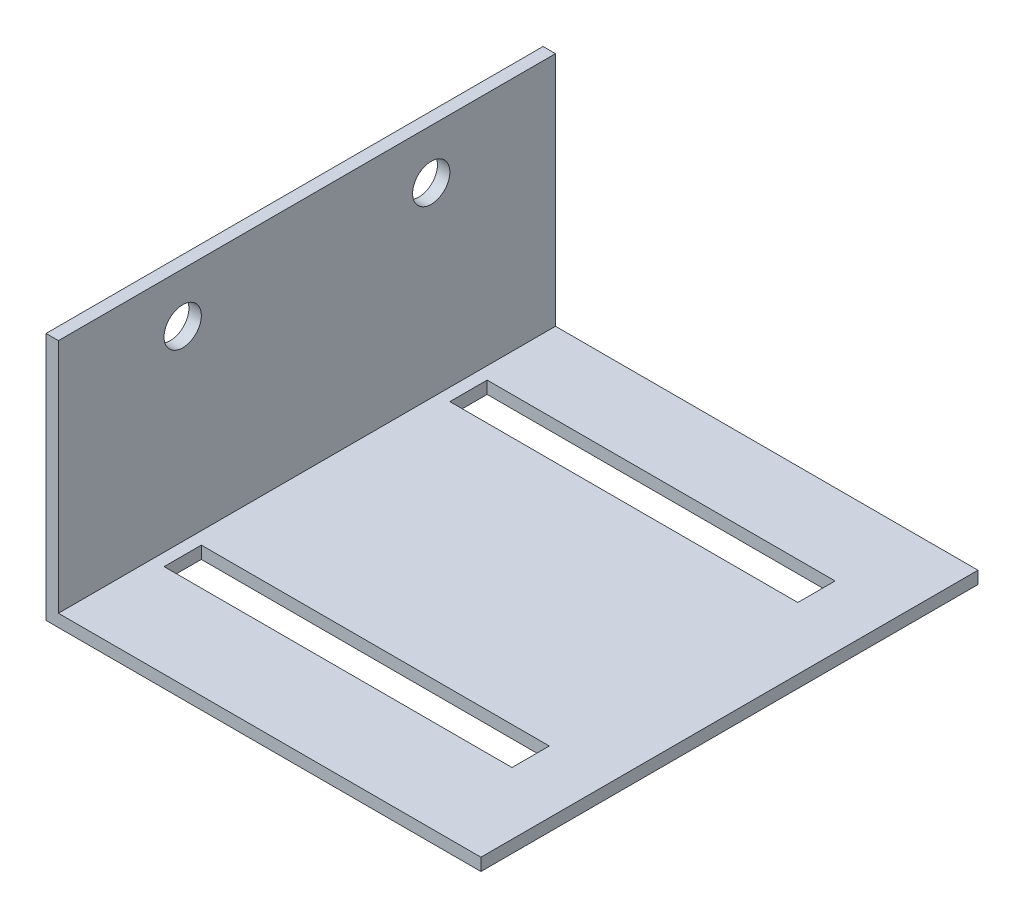
from build123d import *

# Parameters (mm, degrees)
BOSS_EXTRUDE1_DEPTH = 40
SKETCH2_W           = 28
SKETCH2_H           = 3
CUT_EXTRUDE1_DEPTH  = 10
SKETCH3_R           = 1.5
CUT_EXTRUDE2_DEPTH  = 10


with BuildPart() as part:
    # Sketch1 → Boss-Extrude1 (new body)
    with BuildSketch(Plane.XY):
        Polygon((0, 0), (35, 0), (35, 1), (1, 1), (1, 20), (0, 20), align=None)
    extrude(amount=BOSS_EXTRUDE1_DEPTH)

    # Sketch2 → Cut-Extrude1 (cut)
    with BuildSketch(Plane(origin=(0, 1, 0), x_dir=(1, 0, 0), z_dir=(0, 1, 0))):
        with Locations((16, -8)):
            Rectangle(SKETCH2_W, SKETCH2_H)
        with Locations((16, -31)):
            Rectangle(SKETCH2_W, SKETCH2_H)
    extrude(amount=-CUT_EXTRUDE1_DEPTH, mode=Mode.SUBTRACT)

    # Sketch3 → Cut-Extrude2 (cut)
    with BuildSketch(Plane.ZY):
        with Locations((30, 16)):
            Circle(SKETCH3_R)
        with Locations((10, 16)):
            Circle(SKETCH3_R)
    extrude(amount=-CUT_EXTRUDE2_DEPTH, mode=Mode.SUBTRACT)


solid = part.part
